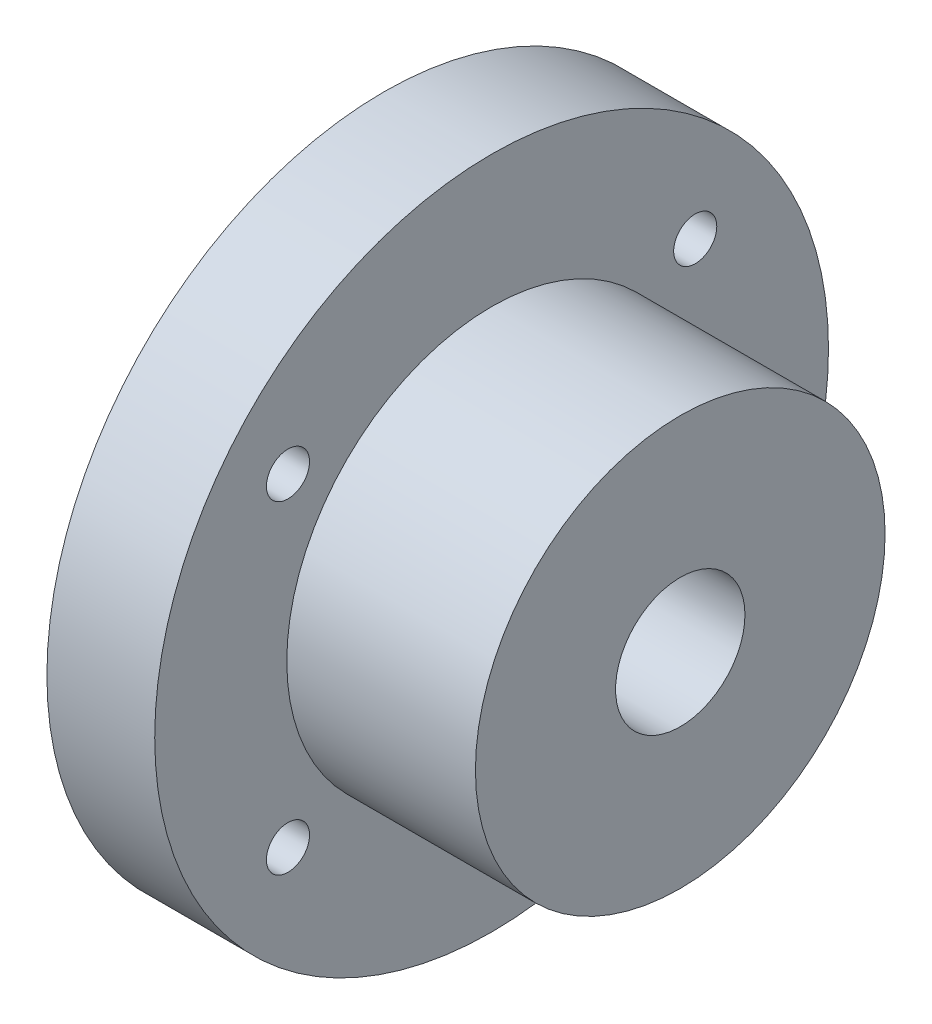
from build123d import *

# Parameters (mm, degrees)
ESBO_O1_R                = 62.5
ESBO_O1_R_2              = 4
RESSALTO_EXTRUS_O1_DEPTH = 20
ESBO_O2_R                = 38
RESSALTO_EXTRUS_O2_DEPTH = 35
ESBO_O4_R                = 12
CORTE_EXTRUS_O1_DEPTH    = 25


with BuildPart() as part:
    # Esboço1 → Ressalto-extrusão1 (new body)
    with BuildSketch(Plane(origin=(0, 0, 0), x_dir=(0, 0, -1), z_dir=(1, 0, 0))):
        Circle(ESBO_O1_R)
        with Locations((37.775, 30)):
            Circle(ESBO_O1_R_2, mode=Mode.SUBTRACT)
        with Locations((-37.775, 30)):
            Circle(ESBO_O1_R_2, mode=Mode.SUBTRACT)
        with Locations((37.775, -30)):
            Circle(ESBO_O1_R_2, mode=Mode.SUBTRACT)
        with Locations((-37.775, -30)):
            Circle(ESBO_O1_R_2, mode=Mode.SUBTRACT)
    extrude(amount=RESSALTO_EXTRUS_O1_DEPTH)

    # Esboço2 → Ressalto-extrusão2 (add)
    with BuildSketch(Plane(origin=(20, 0, 0), x_dir=(0, 0, -1), z_dir=(1, 0, 0))):
        Circle(ESBO_O2_R)
    extrude(amount=RESSALTO_EXTRUS_O2_DEPTH)

    # Esboço4 → Corte-extrusão1 (cut)
    with BuildSketch(Plane(origin=(55, 0, 0), x_dir=(0, 0, -1), z_dir=(1, 0, 0))):
        Circle(ESBO_O4_R)
    extrude(amount=-CORTE_EXTRUS_O1_DEPTH, mode=Mode.SUBTRACT)


solid = part.part
